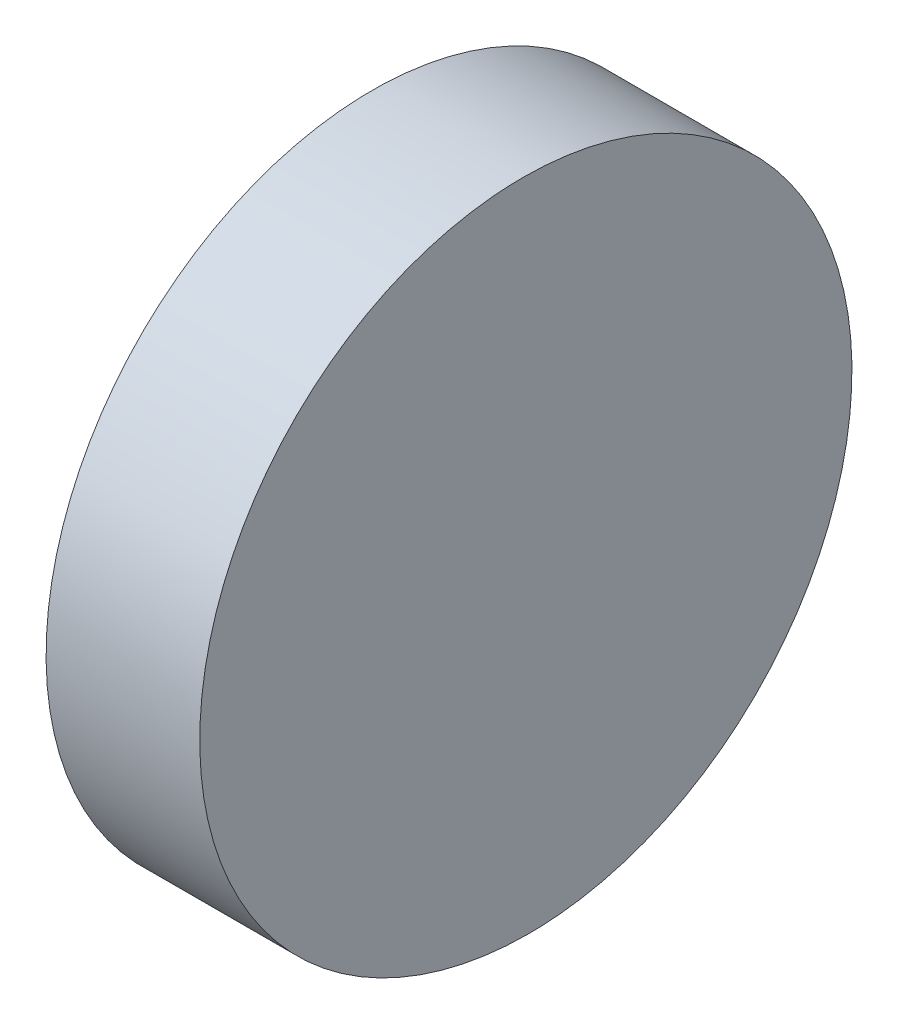
from build123d import *

# Parameters (mm, degrees)
EXTRUDE_1_DEPTH     = 12.5
CUT_EXTRUDE_1_DEPTH = 10


with BuildPart() as part:
    # 草图1 → 凸台-拉伸1 (new body)
    with BuildSketch(Plane.XY):
        Polygon((0, 6.25), (0, -6.25), (3, -6.25), (2.890914153, 6.25), align=None)
    extrude(amount=EXTRUDE_1_DEPTH)

    # 草图2 → 切除-拉伸1 (cut)
    with BuildSketch(Plane.ZY):
        with BuildLine():
            ThreePointArc((6.25, -6.25), (1.830582618, -4.419417382), (0, 0))
            Line((0, 0), (0, -6.25))
            Line((0, -6.25), (6.25, -6.25))
        make_face()
        with BuildLine():
            ThreePointArc((12.5, 0), (10.669417382, -4.419417382), (6.25, -6.25))
            Line((6.25, -6.25), (12.5, -6.25))
            Line((12.5, -6.25), (12.5, 0))
        make_face()
        with BuildLine():
            Line((12.5, 6.25), (6.25, 6.25))
            ThreePointArc((6.25, 6.25), (10.669417382, 4.419417382), (12.5, 0))
            Line((12.5, 0), (12.5, 6.25))
        make_face()
        with BuildLine():
            Line((6.25, 6.25), (0, 6.25))
            Line((0, 6.25), (0, 0))
            ThreePointArc((0, 0), (1.830582618, 4.419417382), (6.25, 6.25))
        make_face()
    extrude(amount=-CUT_EXTRUDE_1_DEPTH, mode=Mode.SUBTRACT)


solid = part.part
